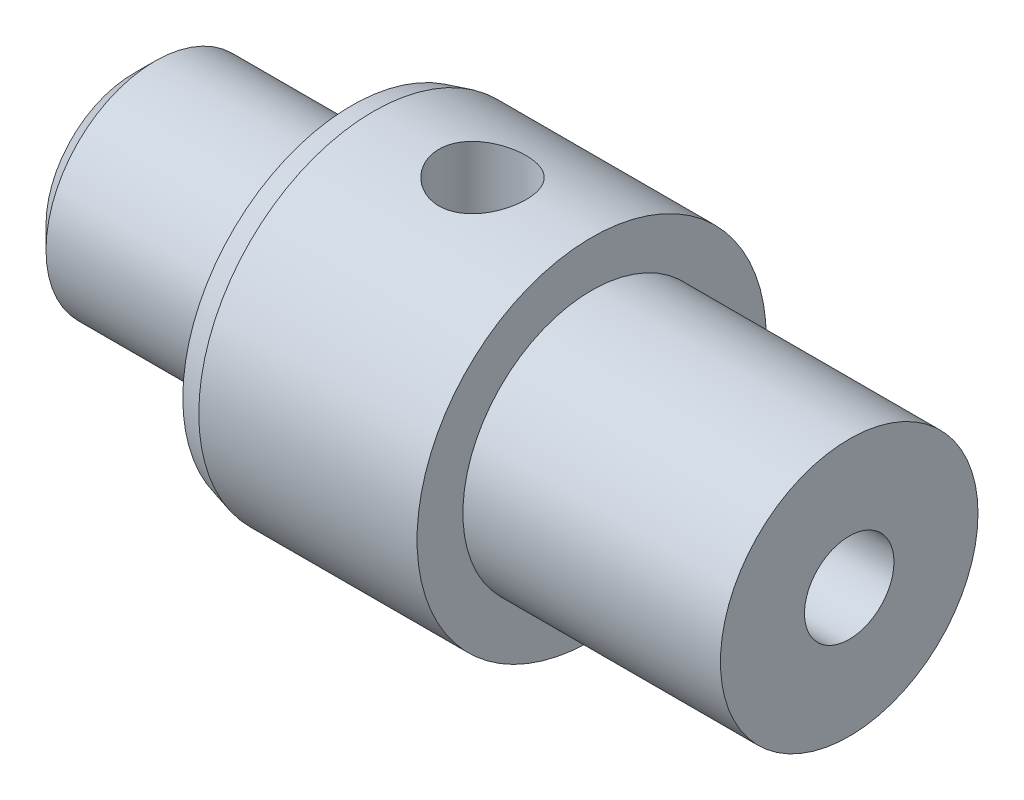
from build123d import *

# Parameters (mm, degrees)
SKETCH1_W                          = 5.5
SKETCH1_H                          = 4
SKETCH2_R                          = 2.5
BOSS_EXTRUDE1_DEPTH                = 5
SKETCH3_R                          = 2.95
BOSS_EXTRUDE2_DEPTH                = 5.9
F_2_0_2_DIAMETER_HOLE1_D           = 2
F_2_0_2_DIAMETER_HOLE1_DEPTH       = 8
TAP_DRILL_FOR_M2_5X0_45_TAP1_D     = 2.05
TAP_DRILL_FOR_M2_5X0_45_TAP1_DEPTH = 6
TAP_DRILL_FOR_M2_5X0_45_TAP1_TIP   = 0.615882135
CHAMFER1_SIZE                      = 0.5
CHAMFER2_SIZE                      = 0.133974596
CHAMFER2_SIZE2                     = 0.5


with BuildPart() as part:
    # Sketch1 → Revolve1 (revolve)
    with BuildSketch(Plane.XY):
        with Locations((7.75, 2)):
            Rectangle(SKETCH1_W, SKETCH1_H)
    revolve(axis=Axis((5, 0, 0), (1, 0, 0)))

    # Sketch2 → Boss-Extrude1 (add)
    with BuildSketch(Plane.ZY.offset(-5)):
        Circle(SKETCH2_R)
    extrude(amount=BOSS_EXTRUDE1_DEPTH)

    # Sketch3 → Boss-Extrude2 (add)
    with BuildSketch(Plane(origin=(10.5, 0, 0), x_dir=(0, 0, -1), z_dir=(1, 0, 0))):
        Circle(SKETCH3_R)
    extrude(amount=BOSS_EXTRUDE2_DEPTH)

    # Ø2.0 (2) Diameter Hole1
    with Locations(Plane(origin=(8, -4, 0), x_dir=(0, 0, -1), z_dir=(0, -1, 0))):
        with Locations((0, 0)):
            Hole(F_2_0_2_DIAMETER_HOLE1_D / 2, depth=F_2_0_2_DIAMETER_HOLE1_DEPTH)

    # Tap Drill for M2.5x0.45 Tap1
    with Locations(Plane(origin=(16.4, 0, 0), x_dir=(0, 0, -1), z_dir=(1, 0, 0))):
        with Locations((0, 0)):
            Hole(TAP_DRILL_FOR_M2_5X0_45_TAP1_D / 2, depth=TAP_DRILL_FOR_M2_5X0_45_TAP1_DEPTH)
            with Locations((0, 0, -(TAP_DRILL_FOR_M2_5X0_45_TAP1_DEPTH + TAP_DRILL_FOR_M2_5X0_45_TAP1_TIP / 2))):  # 118° drill point
                Cone(0, TAP_DRILL_FOR_M2_5X0_45_TAP1_D / 2, TAP_DRILL_FOR_M2_5X0_45_TAP1_TIP, mode=Mode.SUBTRACT)

    # Chamfer1
    chamfer1_edges = [part.edges().sort_by_distance(p)[0] for p in [
        (0, 0, -2.5),
    ]]
    chamfer(chamfer1_edges, length=CHAMFER1_SIZE)

    # Chamfer2
    chamfer2_edges = [part.edges().sort_by_distance(p)[0] for p in [
        (5, -4, 0),
    ]]
    chamfer2_side = [part.faces().sort_by_distance(p)[0] for p in [
        (5, -3.886862915, 0),
    ]]
    chamfer(chamfer2_edges, length=CHAMFER2_SIZE, length2=CHAMFER2_SIZE2, reference=chamfer2_side[0])


solid = part.part
